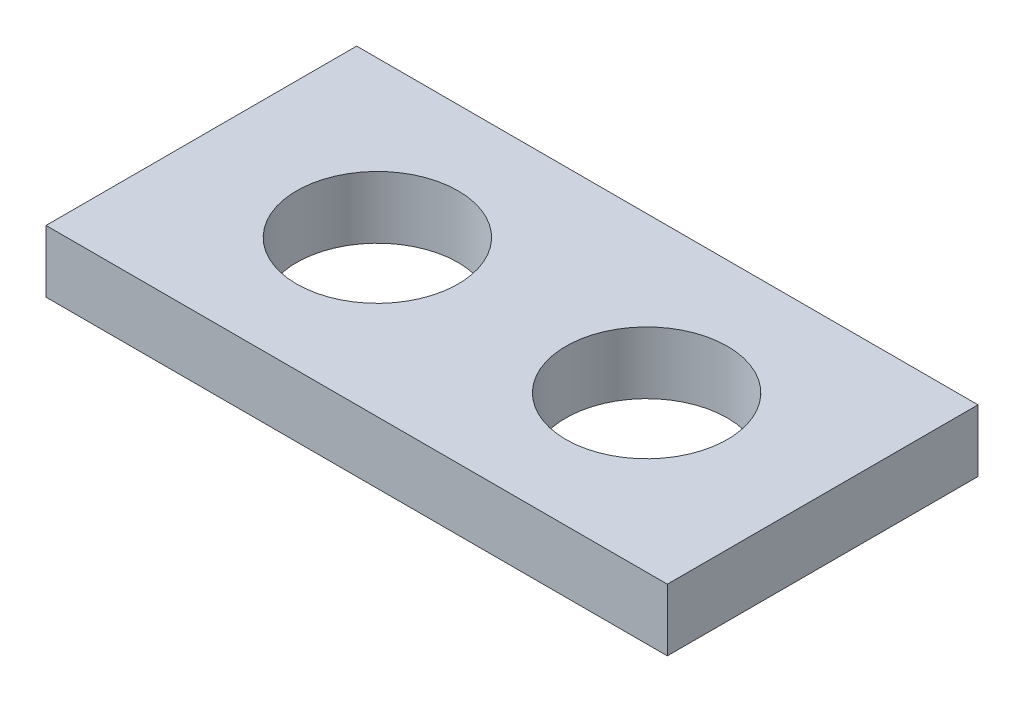
from build123d import *

# Parameters (mm, degrees)
SKETCH1_W           = 30
SKETCH1_H           = 15
BOSS_EXTRUDE1_DEPTH = 3
CUT_EXTRUDE1_START  = -4
SKETCH2_R           = 3.9
CUT_EXTRUDE1_DEPTH  = 5


with BuildPart() as part:
    # Sketch1 → Boss-Extrude1 (new body)
    with BuildSketch(Plane(origin=(0, 0, 0), x_dir=(1, 0, 0), z_dir=(0, 1, 0))):
        Rectangle(SKETCH1_W, SKETCH1_H)
    extrude(amount=BOSS_EXTRUDE1_DEPTH)

    # Sketch2 → Cut-Extrude1 (cut)
    with BuildSketch(Plane(origin=(0, 3, 0), x_dir=(1, 0, 0), z_dir=(0, 1, 0)).offset(CUT_EXTRUDE1_START)):
        with Locations((-6.5, 0)):
            Circle(SKETCH2_R)
    cut_extrude1 = extrude(amount=CUT_EXTRUDE1_DEPTH, mode=Mode.SUBTRACT)

    # Mirror1: Cut-Extrude1 across plane
    add(cut_extrude1.mirror(Plane(origin=(0, 0, 0), x_dir=(0, 0, 1), z_dir=(1, 0, 0))), mode=Mode.SUBTRACT)


solid = part.part
